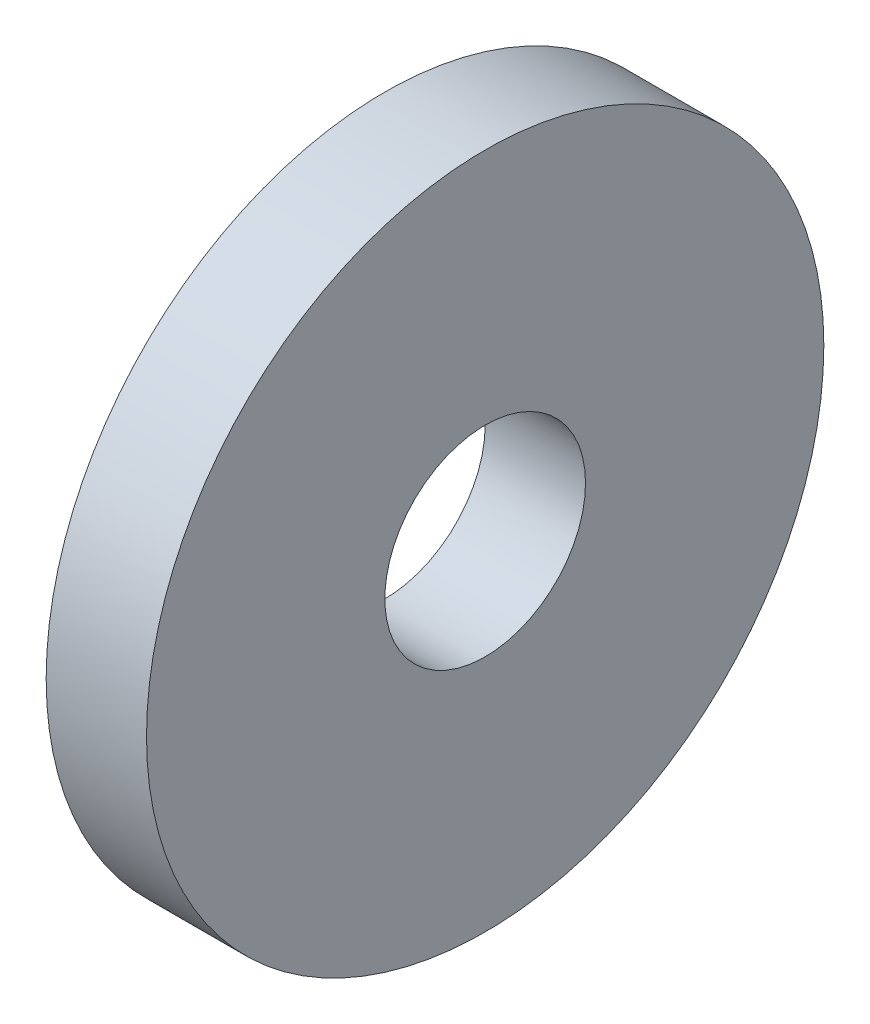
from build123d import *

# Parameters (mm, degrees)
SKETCH1_R           = 6.75
BOSS_EXTRUDE1_DEPTH = 2
SKETCH2_R           = 2
CUT_EXTRUDE1_DEPTH  = 3


with BuildPart() as part:
    # Sketch1 → Boss-Extrude1 (new body)
    with BuildSketch(Plane(origin=(0, 0, 0), x_dir=(0, 0, -1), z_dir=(1, 0, 0))):
        Circle(SKETCH1_R)
    extrude(amount=BOSS_EXTRUDE1_DEPTH)

    # Sketch2 → Cut-Extrude1 (cut, through all)
    with BuildSketch(Plane(origin=(2, 0, 0), x_dir=(0, 0, -1), z_dir=(1, 0, 0))):
        Circle(SKETCH2_R)
    extrude(amount=-CUT_EXTRUDE1_DEPTH, mode=Mode.SUBTRACT)


solid = part.part
